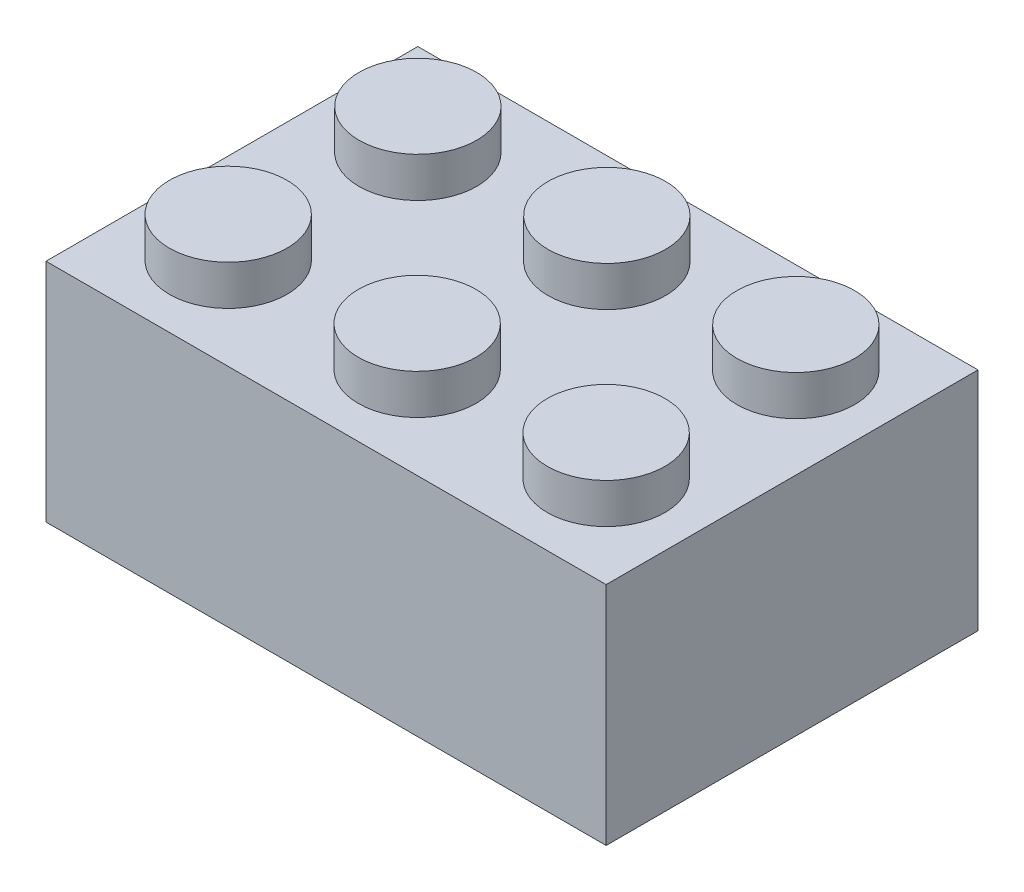
from build123d import *

# Parameters (mm, degrees)
SKETCH_5_W          = 23.8
SKETCH_5_H          = 15.8
EXTRUDE_2_DEPTH     = 9.6
SKETCH_6_R          = 2.5
EXTRUDE_3_DEPTH     = 1.7
SKETCH_7_R          = 2.6
CUT_EXTRUDE_1_DEPTH = 1.8


with BuildPart() as part:
    # Эскиз5 → Бобышка-Вытянуть2 (new body)
    with BuildSketch(Plane(origin=(0, 0, 0), x_dir=(1, 0, 0), z_dir=(0, 1, 0))):
        with Locations((11.9, 7.9)):
            Rectangle(SKETCH_5_W, SKETCH_5_H)
    extrude(amount=EXTRUDE_2_DEPTH)

    # Эскиз6 → Бобышка-Вытянуть3 (add)
    with BuildSketch(Plane(origin=(0, 9.6, 0), x_dir=(1, 0, 0), z_dir=(0, 1, 0))):
        with Locations((3.9, 11.9)):
            Circle(SKETCH_6_R)
        with Locations((11.929146399, 11.9)):
            Circle(SKETCH_6_R)
        with Locations((19.958292799, 11.9)):
            Circle(SKETCH_6_R)
        with Locations((11.870853601, 3.9)):
            Circle(SKETCH_6_R)
        with Locations((19.9, 3.9)):
            Circle(SKETCH_6_R)
        with Locations((3.841707201, 3.9)):
            Circle(SKETCH_6_R)
    extrude(amount=EXTRUDE_3_DEPTH)

    # Эскиз7 → Вырез-Вытянуть1 (cut)
    with BuildSketch(Plane.XZ):
        with Locations((3.9, -3.9)):
            Circle(SKETCH_7_R)
        with Locations((11.9, -3.9)):
            Circle(SKETCH_7_R)
        with Locations((19.9, -3.9)):
            Circle(SKETCH_7_R)
        with Locations((11.9, -11.9)):
            Circle(SKETCH_7_R)
        with Locations((19.9, -11.9)):
            Circle(SKETCH_7_R)
        with Locations((3.9, -11.9)):
            Circle(SKETCH_7_R)
    extrude(amount=-CUT_EXTRUDE_1_DEPTH, mode=Mode.SUBTRACT)


solid = part.part
